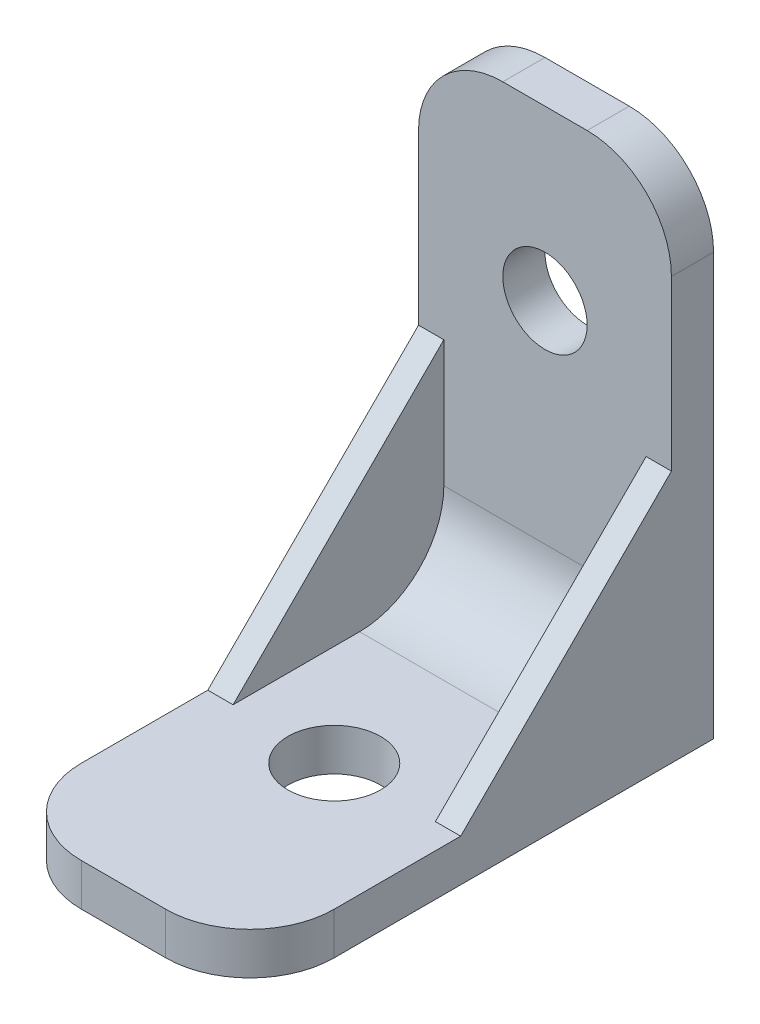
from build123d import *

# Parameters (mm, degrees)
BOSS_EXTRUDE1_DEPTH = 15
SKETCH2_R           = 5.5
CUT_EXTRUDE1_DEPTH  = 30
SKETCH3_R           = 5
CUT_EXTRUDE2_DEPTH  = 30
FILLET1_R           = 10
BOSS_EXTRUDE2_DEPTH = 3
FILLET2_R           = 10


with BuildPart() as part:
    # Sketch1 → Boss-Extrude1 (new body, symmetric)
    with BuildSketch(Plane(origin=(0, 0, 0), x_dir=(0, 0, -1), z_dir=(1, 0, 0))):
        Polygon((-55, 5), (-5, 5), (-5, 60), (0, 60), (0, 0), (-55, 0), align=None)
    extrude(amount=BOSS_EXTRUDE1_DEPTH, both=True)

    # Sketch2 → Cut-Extrude1 (cut)
    with BuildSketch(Plane(origin=(0, 5, 0), x_dir=(1, 0, 0), z_dir=(0, 1, 0))):
        with Locations((0, -30)):
            Circle(SKETCH2_R)
    extrude(amount=-CUT_EXTRUDE1_DEPTH, mode=Mode.SUBTRACT)

    # Sketch3 → Cut-Extrude2 (cut)
    with BuildSketch(Plane.XY.offset(5)):
        with Locations((0, 40)):
            Circle(SKETCH3_R)
    extrude(amount=-CUT_EXTRUDE2_DEPTH, mode=Mode.SUBTRACT)

    # Fillet1
    fillet1_edges = [part.edges().sort_by_distance(p)[0] for p in [
        (15, 60, 2.5),
        (15, 2.5, 55),
        (-15, 60, 2.5),
        (-15, 2.5, 55),
    ]]
    fillet(fillet1_edges, radius=FILLET1_R)

    # Sketch4 → Boss-Extrude2 (add)
    with BuildSketch(Plane.ZY.offset(15)):
        Polygon((30, 5), (5, 30), (5, 5), align=None)
    boss_extrude2 = extrude(amount=-BOSS_EXTRUDE2_DEPTH)

    # Mirror1: Boss-Extrude2 across plane
    add(boss_extrude2.mirror(Plane(origin=(0, 0, 0), x_dir=(0, 0, 1), z_dir=(1, 0, 0))))

    # Fillet2
    fillet2_edges = [part.edges().sort_by_distance(p)[0] for p in [
        (0, 5, 5),
    ]]
    fillet(fillet2_edges, radius=FILLET2_R)


solid = part.part
